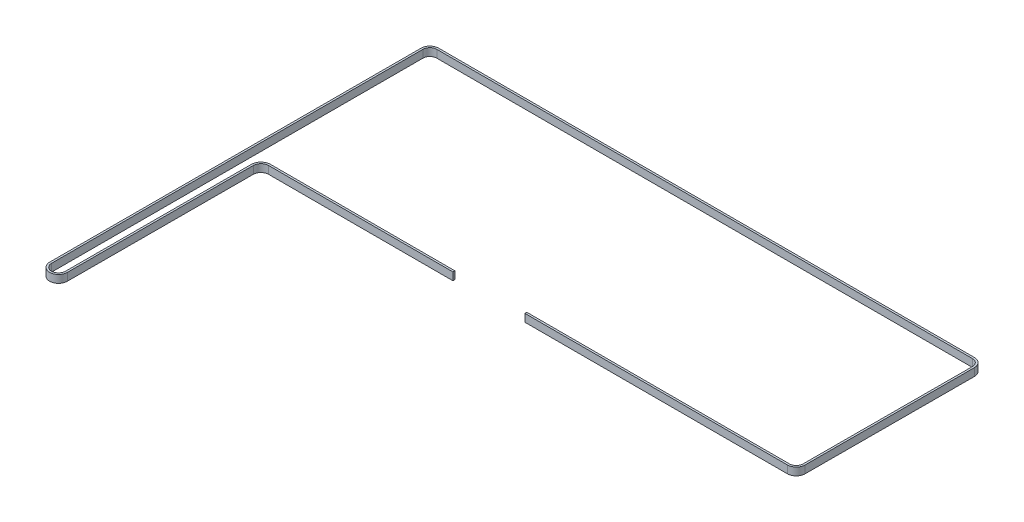
from build123d import *

# Parameters (mm, degrees)
BOSS_EXTRUDE1_DEPTH = 6


with BuildPart() as part:
    # Sketch1 → Boss-Extrude1 (new body)
    with BuildSketch(Plane.XZ.offset(-323)):
        with BuildLine():
            Line((-52.025054896, -21.507337011), (-195.6, -21.507337011))
            ThreePointArc((-195.6, -21.507337011), (-199.838234915, -19.754378899), (-201.599987073, -15.519791945))
            Line((-201.599987073, -15.519791945), (-201.900014866, 129.014323174))
            ThreePointArc((-201.900014866, 129.014323174), (-208.810742902, 135.899991637), (-215.699996282, 128.992837374))
            Line((-215.699996282, 128.992837374), (-215.399996282, -160.007162626))
            ThreePointArc((-215.399996282, -160.007162626), (-213.376503762, -164.881568504), (-208.5, -166.9))
            Line((-208.5, -166.9), (208.8, -166.9))
            ThreePointArc((208.8, -166.9), (213.684597243, -164.873469993), (215.699982056, -159.984263701))
            Line((215.699982056, -159.984263701), (215.399982056, -28.441600712))
            ThreePointArc((215.399982056, -28.441600712), (213.373469993, -23.572739768), (208.5, -21.557337011))
            Line((208.5, -21.557337011), (3.974945104, -21.557337011))
            Line((3.974945104, -21.557337011), (3.974945104, -23.057337011))
            Line((3.974945104, -23.057337011), (208.5, -23.057337011))
            ThreePointArc((208.5, -23.057337011), (212.314019994, -24.634608733), (213.899985957, -28.445021647))
            Line((213.899985957, -28.445021647), (214.199985957, -159.987684636))
            ThreePointArc((214.199985957, -159.987684636), (212.622728277, -163.814019994), (208.8, -165.4))
            Line((208.8, -165.4), (-208.5, -165.4))
            ThreePointArc((-208.5, -165.4), (-212.316394249, -163.82035796), (-213.899997091, -160.005605533))
            Line((-213.899997091, -160.005605533), (-214.199997091, 128.994394467))
            ThreePointArc((-214.199997091, 128.994394467), (-208.808407488, 134.399993455), (-203.400011634, 129.011209441))
            Line((-203.400011634, 129.011209441), (-203.099983841, -15.522905679))
            ThreePointArc((-203.099983841, -15.522905679), (-200.897793644, -20.816139371), (-195.6, -23.007337011))
            Line((-195.6, -23.007337011), (-52.025054896, -23.007337011))
            Line((-52.025054896, -23.007337011), (-52.025054896, -21.507337011))
        make_face()
    extrude(amount=-BOSS_EXTRUDE1_DEPTH)


solid = part.part
